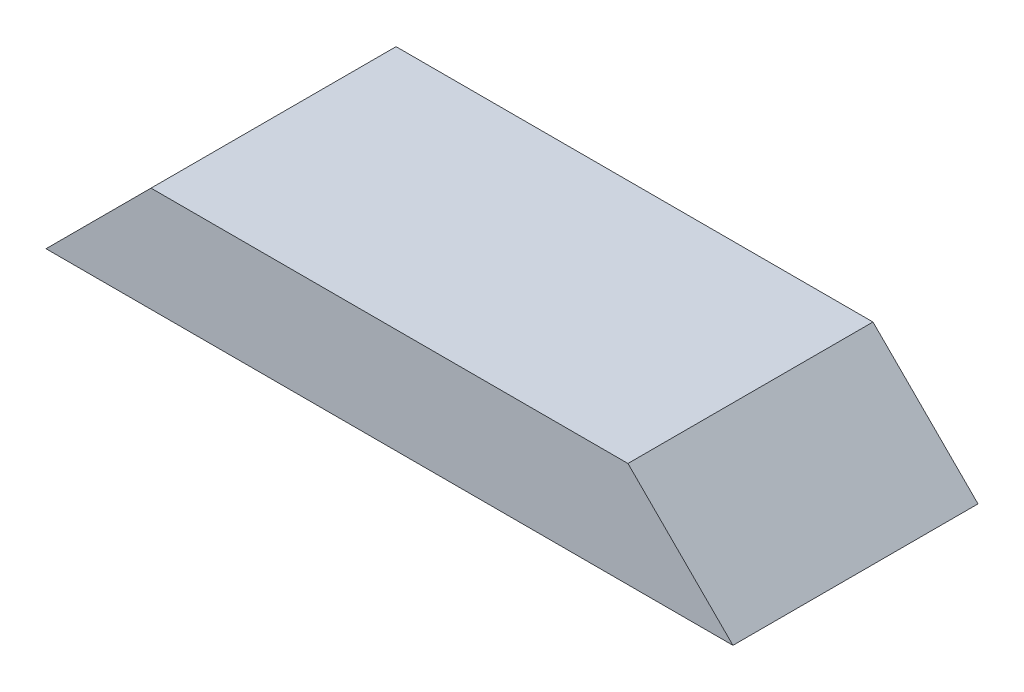
from build123d import *

# Parameters (mm, degrees)
SKETCH1_W           = 249.2375
SKETCH1_H           = 88.9
BOSS_EXTRUDE1_DEPTH = 38.1
CUT_EXTRUDE1_DEPTH  = 89.9


with BuildPart() as part:
    # Sketch1 → Boss-Extrude1 (new body)
    with BuildSketch(Plane(origin=(0, 0, 0), x_dir=(1, 0, 0), z_dir=(0, 1, 0))):
        with Locations((124.61875, 44.45)):
            Rectangle(SKETCH1_W, SKETCH1_H)
    extrude(amount=BOSS_EXTRUDE1_DEPTH)

    # Sketch2 → Cut-Extrude1 (cut, through all)
    with BuildSketch(Plane.XY):
        Polygon((0, 0), (38.1, 38.1), (0, 38.1), align=None)
        Polygon((249.2375, 0), (249.2375, 38.1), (211.1375, 38.1), align=None)
    extrude(amount=-CUT_EXTRUDE1_DEPTH, mode=Mode.SUBTRACT)


solid = part.part
